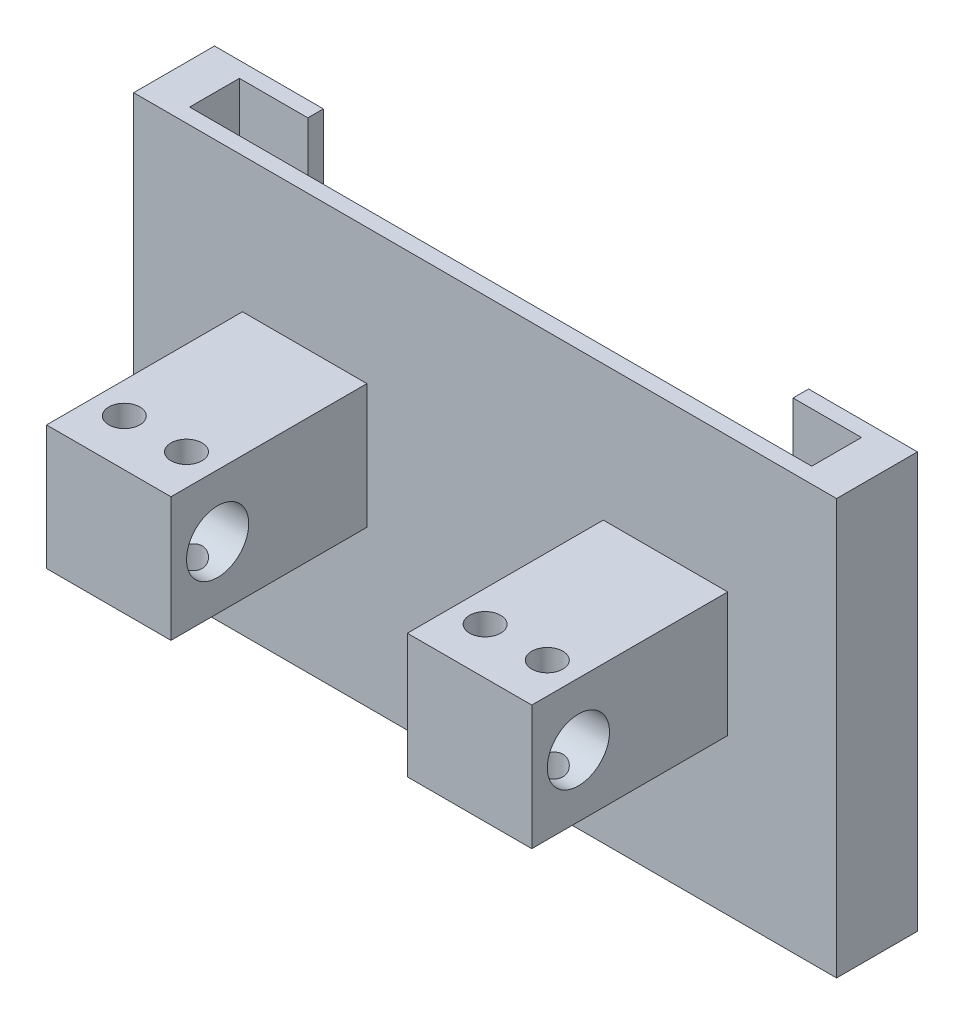
from build123d import *

# Parameters (mm, degrees)
SKETCH3_W               = 226
SKETCH3_H               = 133.5
BOSS_EXTRUDE1_DEPTH     = 26
SKETCH4_W               = 200
SKETCH4_H               = 16
CUT_EXTRUDE2_DEPTH      = 64.5
CUT_EXTRUDE2_DEPTH_BACK = 60
SKETCH6_W               = 40
SKETCH6_H               = 40
BOSS_EXTRUDE5_DEPTH     = 63
SKETCH7_R               = 10
CUT_EXTRUDE3_DEPTH      = 260
SKETCH13_R              = 5
CUT_EXTRUDE6_DEPTH      = 91
SKETCH10_W              = 156
SKETCH10_H              = 103.5
CUT_EXTRUDE5_DEPTH      = 5


with BuildPart() as part:
    # Sketch3 → Boss-Extrude1 (new body)
    with BuildSketch(Plane.XY):
        with Locations((0, -3.25)):
            Rectangle(SKETCH3_W, SKETCH3_H)
    extrude(amount=BOSS_EXTRUDE1_DEPTH)

    # Sketch4 → Cut-Extrude2 (cut, two sides)
    with BuildSketch(Plane(origin=(0, 0, 0), x_dir=(1, 0, 0), z_dir=(0, 1, 0))) as cut_extrude2_sk:
        with Locations((0, -13)):
            Rectangle(SKETCH4_W, SKETCH4_H)
    extrude(amount=CUT_EXTRUDE2_DEPTH, mode=Mode.SUBTRACT)
    extrude(cut_extrude2_sk.sketch, amount=-CUT_EXTRUDE2_DEPTH_BACK, mode=Mode.SUBTRACT)

    # Sketch6 → Boss-Extrude5 (add)
    with BuildSketch(Plane.XY.offset(26)):
        with Locations((-58, 0)):
            Rectangle(SKETCH6_W, SKETCH6_H)
        with Locations((58, 0)):
            Rectangle(SKETCH6_W, SKETCH6_H)
    extrude(amount=BOSS_EXTRUDE5_DEPTH)

    # Sketch7 → Cut-Extrude3 (cut)
    with BuildSketch(Plane(origin=(113, 0, 0), x_dir=(0, 0, -1), z_dir=(1, 0, 0))):
        with Locations((-74, 0)):
            Circle(SKETCH7_R)
    extrude(amount=-CUT_EXTRUDE3_DEPTH, mode=Mode.SUBTRACT)

    # Sketch13 → Cut-Extrude6 (cut, through all)
    with BuildSketch(Plane(origin=(0, 20, 0), x_dir=(1, 0, 0), z_dir=(0, 1, 0))):
        with Locations((-68, -74)):
            Circle(SKETCH13_R)
        with Locations((-48, -74)):
            Circle(SKETCH13_R)
        with Locations((48, -74)):
            Circle(SKETCH13_R)
        with Locations((68, -74)):
            Circle(SKETCH13_R)
    extrude(amount=-CUT_EXTRUDE6_DEPTH, mode=Mode.SUBTRACT)

    # Sketch10 → Cut-Extrude5 (cut)
    with BuildSketch(Plane(origin=(0, 0, 0), x_dir=(-1, 0, 0), z_dir=(0, 0, -1))):
        with Locations((0, 11.75)):
            Rectangle(SKETCH10_W, SKETCH10_H)
    extrude(amount=-CUT_EXTRUDE5_DEPTH, mode=Mode.SUBTRACT)


solid = part.part
